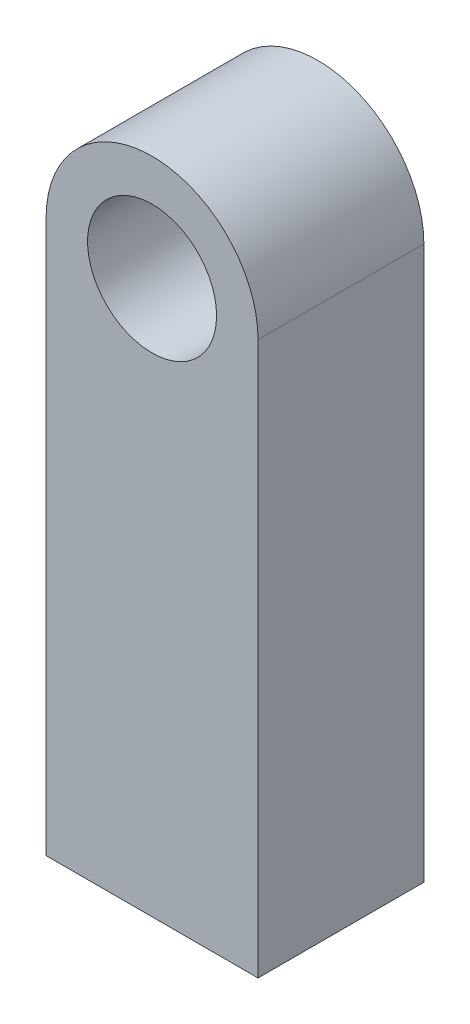
from build123d import *

# Parameters (mm, degrees)
CROQUIS1_R              = 1.75
SALIENTE_EXTRUIR1_DEPTH = 4.5


with BuildPart() as part:
    # Croquis1 → Saliente-Extruir1 (new body)
    with BuildSketch(Plane.XY):
        with BuildLine():
            Line((-2.875, 7.5), (-2.875, -7.5))
            Line((-2.875, -7.5), (2.875, -7.5))
            Line((2.875, -7.5), (2.875, 7.5))
            ThreePointArc((2.875, 7.5), (0, 10.375), (-2.875, 7.5))
        make_face()
        with Locations((0, 7.5)):
            Circle(CROQUIS1_R, mode=Mode.SUBTRACT)
    extrude(amount=SALIENTE_EXTRUIR1_DEPTH)


solid = part.part
